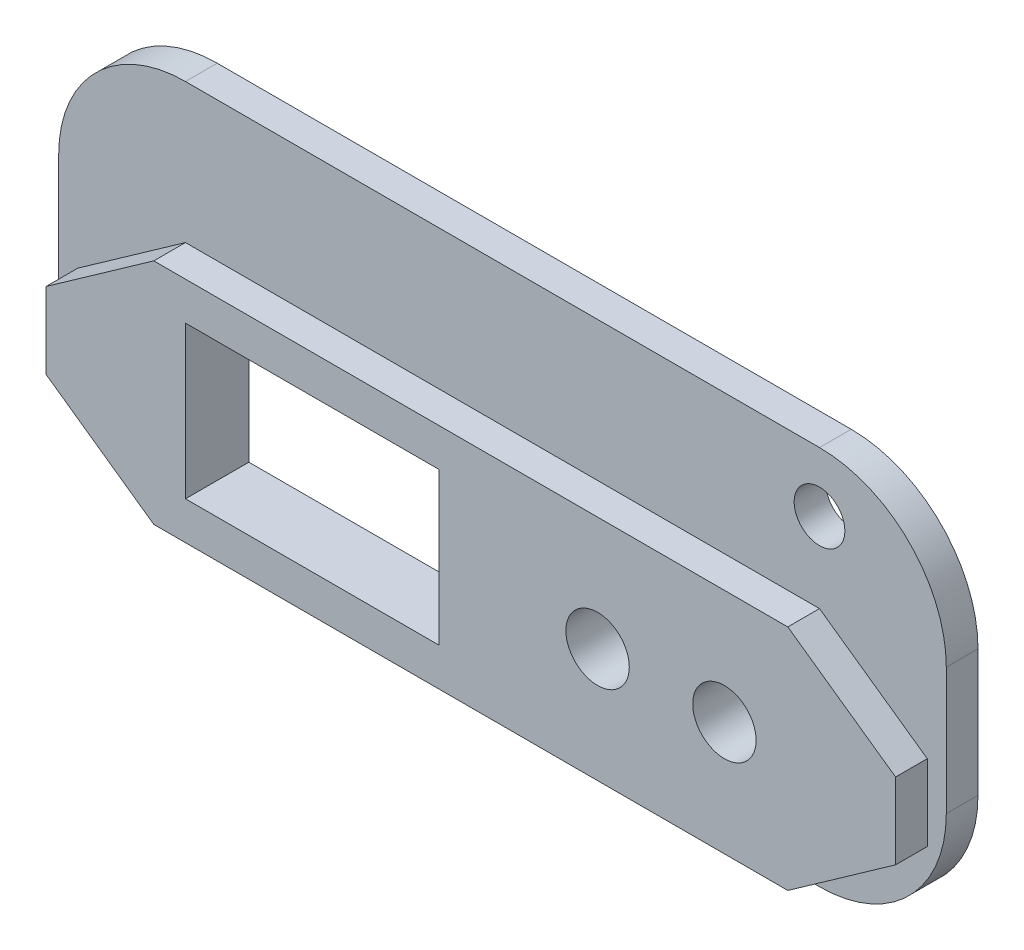
from build123d import *

# Parameters (mm, degrees)
BOSS_EXTRUDE1_DEPTH     = 2.5
SKETCH2_W               = 70
SKETCH2_H               = 30
BOSS_EXTRUDE2_DEPTH     = 2.5
SKETCH3_R               = 2
CUT_EXTRUDE1_DEPTH      = 2.5
FILLET1_R               = 10
SKETCH4_R               = 2.5
SKETCH4_W               = 20
SKETCH4_H               = 12
CUT_EXTRUDE2_DEPTH      = 3.5
CUT_EXTRUDE2_DEPTH_BACK = 3.5


with BuildPart() as part:
    # Sketch1 → Boss-Extrude1 (new body)
    with BuildSketch(Plane.XY):
        Polygon((-33.5, 3), (-25, 9), (25, 9), (33.5, 3), (33.5, -3), (25, -9), (-25, -9), (-33.5, -3), align=None)
    extrude(amount=BOSS_EXTRUDE1_DEPTH)

    # Sketch2 → Boss-Extrude2 (add)
    with BuildSketch(Plane.XY):
        with Locations((0, 5)):
            Rectangle(SKETCH2_W, SKETCH2_H)
    extrude(amount=-BOSS_EXTRUDE2_DEPTH)

    # Sketch3 → Cut-Extrude1 (cut)
    with BuildSketch(Plane.XY):
        with Locations((25, 15.3)):
            Circle(SKETCH3_R)
    extrude(amount=-CUT_EXTRUDE1_DEPTH, mode=Mode.SUBTRACT)

    # Fillet1
    fillet1_edges = [part.edges().sort_by_distance(p)[0] for p in [
        (35, 20, -1.25),
        (35, -10, -1.25),
        (-35, -10, -1.25),
        (-35, 20, -1.25),
    ]]
    fillet(fillet1_edges, radius=FILLET1_R)

    # Sketch4 → Cut-Extrude2 (cut, two sides)
    with BuildSketch(Plane.XY) as cut_extrude2_sk:
        with Locations((10, 0)):
            Circle(SKETCH4_R)
        with Locations((20, 0)):
            Circle(SKETCH4_R)
        with Locations((-12.5, 0)):
            Rectangle(SKETCH4_W, SKETCH4_H)
    extrude(amount=CUT_EXTRUDE2_DEPTH, mode=Mode.SUBTRACT)
    extrude(cut_extrude2_sk.sketch, amount=-CUT_EXTRUDE2_DEPTH_BACK, mode=Mode.SUBTRACT)


solid = part.part
